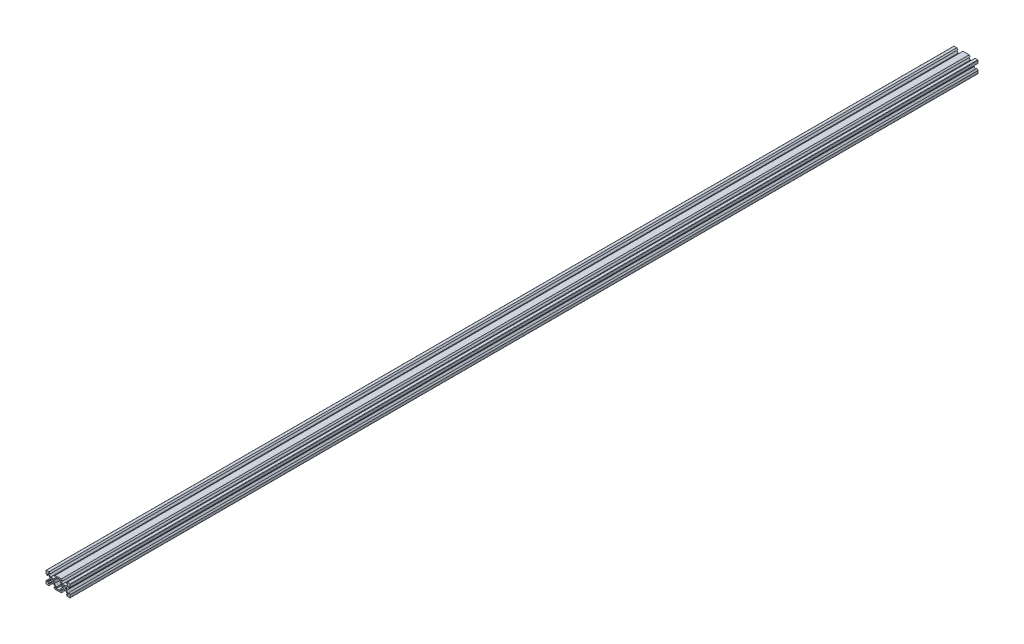
from build123d import *

# Parameters (mm, degrees)
SKETCH1_R           = 2.1
BOSS_EXTRUDE1_DEPTH = 1500
FILLET1_R           = 0.5


with BuildPart() as part:
    # Sketch1 → Boss-Extrude1 (new body)
    with BuildSketch(Plane.XY):
        Polygon((-20, -10), (-15.5, -10), (-15.1, -10), (-13.1, -8), (-15.5, -8), (-15.5, -6.560660172), (-12.539339828, -3.6), (-7.460660172, -3.6), (-4.5, -6.560660172), (-4.5, -8), (-6.9, -8), (-4.9, -10), (5.313777138, -10), (7.313777138, -8), (4.5, -8), (4.5, -6.560660172), (7.460660172, -3.6), (12.539339828, -3.6), (15.5, -6.560660172), (15.5, -8), (13.513777138, -8), (15.1, -10), (15.5, -10), (20, -10), (20, -5.5), (20, -5.1), (18, -3.1), (18, -5.5), (16.560660172, -5.5), (13.6, -2.539339828), (13.6, 2.539339828), (16.560660172, 5.5), (18, 5.5), (18, 3.1), (20, 5.1), (20, 5.5), (20, 10), (15.5, 10), (15.1, 10), (13.1, 8), (15.5, 8), (15.5, 6.560660172), (12.539339828, 3.6), (7.460660172, 3.6), (4.5, 6.560660172), (4.5, 8), (7.313777138, 8), (5.313777138, 10), (-4.9, 10), (-6.9, 8), (-4.5, 8), (-4.5, 6.560660172), (-7.460660172, 3.6), (-12.539339828, 3.6), (-15.5, 6.560660172), (-15.5, 8), (-13.1, 8), (-15.1, 10), (-15.5, 10), (-20, 10), (-20, 5.5), (-20, 5.1), (-18, 3.1), (-18, 5.5), (-16.560660172, 5.5), (-13.6, 2.539339828), (-13.6, -2.539339828), (-16.560660172, -5.5), (-18, -5.5), (-18, -3.1), (-20, -5.1), (-20, -5.5), align=None)
        with Locations((-10, 0)):
            Circle(SKETCH1_R, mode=Mode.SUBTRACT)
        with Locations((10, 0)):
            Circle(SKETCH1_R, mode=Mode.SUBTRACT)
        Polygon((3, -5.939339828), (3, -8), (-3, -8), (-3, -5.939339828), (-6.4, -2.539339828), (-6.4, 2.539339828), (-3, 5.939339828), (-3, 8), (3, 8), (3, 5.939339828), (6.4, 2.539339828), (6.4, -2.539339828), align=None, mode=Mode.SUBTRACT)
    extrude(amount=BOSS_EXTRUDE1_DEPTH)

    # Fillet1
    fillet1_edges = [part.edges().sort_by_distance(p)[0] for p in [
        (-20, 10, 750),
        (20, 10, 750),
        (20, -10, 750),
        (-20, -10, 750),
    ]]
    fillet(fillet1_edges, radius=FILLET1_R)


solid = part.part
